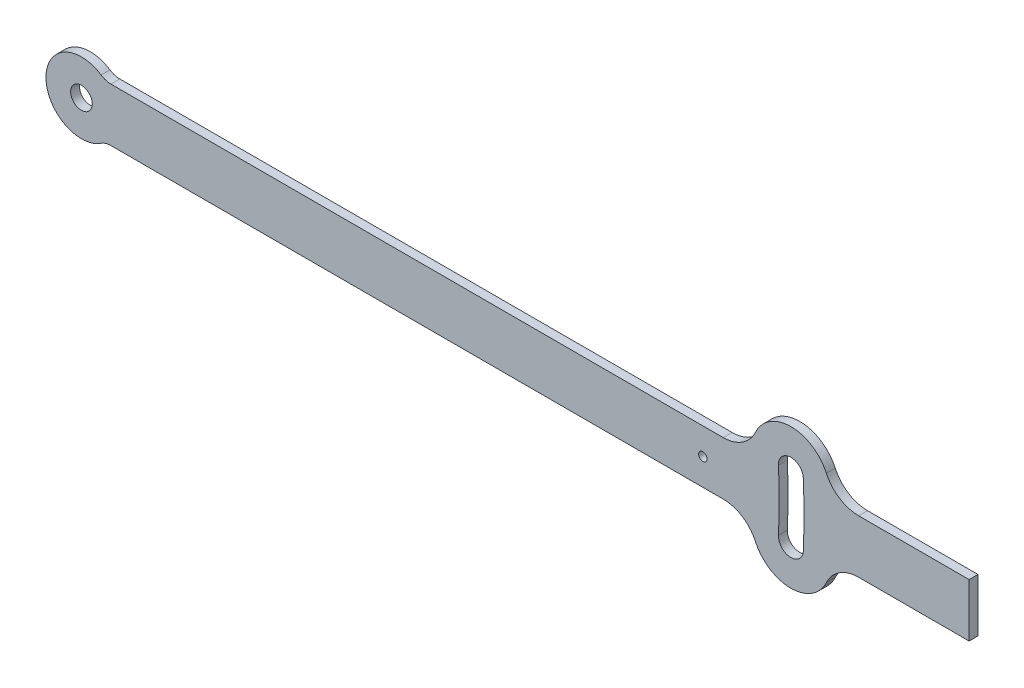
from build123d import *

# Parameters (mm, degrees)
ESQUISSE1_R        = 6.1
ESQUISSE1_R_2      = 2.4
BOSS_EXTRU_1_DEPTH = 5
CONG_1_R           = 10
CONG_2_R           = 20


with BuildPart() as part:
    # Esquisse1 → Boss.-Extru.1 (new body)
    with BuildSketch(Plane.XY):
        with BuildLine():
            Line((13.228756555, 15), (377.702263695, 15))
            ThreePointArc((377.702263695, 15), (377.67197868, 15.744094767), (377.640227758, 16.488128424))
            ThreePointArc((377.640227758, 16.488128424), (398.659662111, 39.426815821), (421.598349508, 18.407381468))
            ThreePointArc((421.598349508, 18.407381468), (421.669280552, 16.703827075), (421.733328064, 15))
            Line((421.733328064, 15), (500, 15))
            Line((500, 15), (500, -15))
            Line((500, -15), (421.733328064, -15))
            ThreePointArc((421.733328064, -15), (421.669280552, -16.703827075), (421.598349508, -18.407381468))
            ThreePointArc((421.598349508, -18.407381468), (398.659662111, -39.426815821), (377.640227758, -16.488128424))
            ThreePointArc((377.640227758, -16.488128424), (377.67197868, -15.744094767), (377.702263695, -15))
            Line((377.702263695, -15), (13.228756555, -15))
            ThreePointArc((13.228756555, -15), (-20, 0), (13.228756555, 15))
        make_face()
        Circle(ESQUISSE1_R, mode=Mode.SUBTRACT)
        with Locations((350, 0)):
            Circle(ESQUISSE1_R_2, mode=Mode.SUBTRACT)
        with BuildLine():
            ThreePointArc((392.625951082, -17.142419235), (393, 0), (392.625951082, 17.142419235))
            ThreePointArc((392.625951082, 17.142419235), (399.313952921, 24.441092497), (406.612626184, 17.753090658))
            ThreePointArc((406.612626184, 17.753090658), (407, 0), (406.612626184, -17.753090658))
            ThreePointArc((406.612626184, -17.753090658), (399.313952921, -24.441092497), (392.625951082, -17.142419235))
        make_face(mode=Mode.SUBTRACT)
    extrude(amount=BOSS_EXTRU_1_DEPTH)

    # Congé1
    cong_1_edges = [part.edges().sort_by_distance(p)[0] for p in [
        (13.228756555, 15, 2.5),
        (13.228756555, -15, 2.5),
    ]]
    fillet(cong_1_edges, radius=CONG_1_R)

    # Congé2
    cong_2_edges = [part.edges().sort_by_distance(p)[0] for p in [
        (421.733328064, 15, 2.5),
        (421.733328064, -15, 2.5),
        (377.702263695, 15, 2.5),
        (377.702263695, -15, 2.5),
    ]]
    fillet(cong_2_edges, radius=CONG_2_R)


solid = part.part
